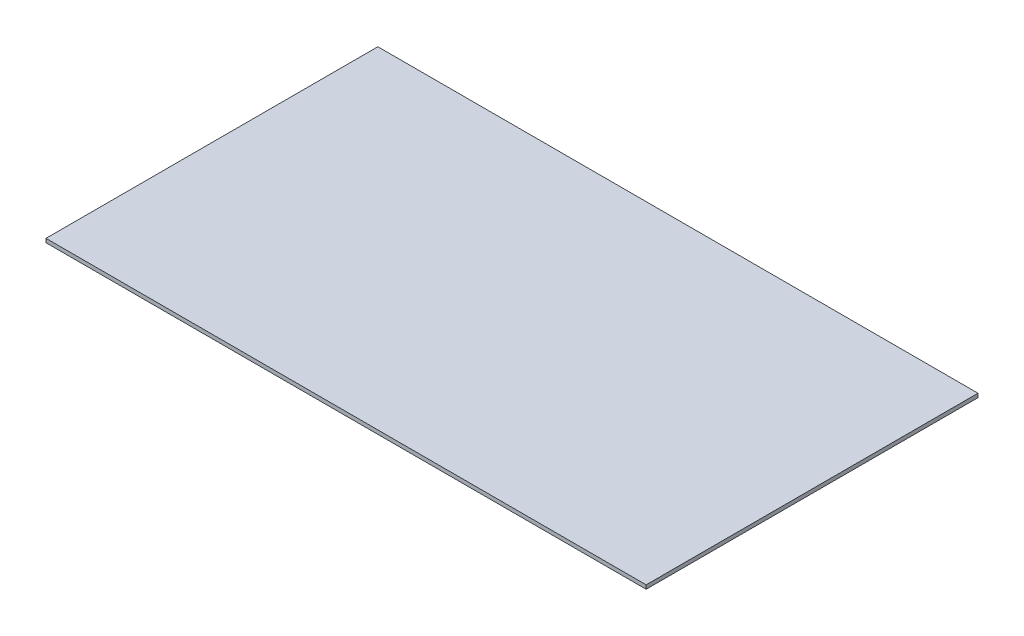
from build123d import *

# Parameters (mm, degrees)
SKETCH1_W      = 249.120634921
SKETCH1_H      = 137.751803752
EXTRUDE1_DEPTH = 1.6


with BuildPart() as part:
    # Sketch1 → Extrude1 (new body)
    with BuildSketch(Plane(origin=(0, 0, 0), x_dir=(1, 0, 0), z_dir=(0, 1, 0))):
        with Locations((-3.852380953, 4.786291486)):
            Rectangle(SKETCH1_W, SKETCH1_H)
    extrude(amount=EXTRUDE1_DEPTH)


solid = part.part
